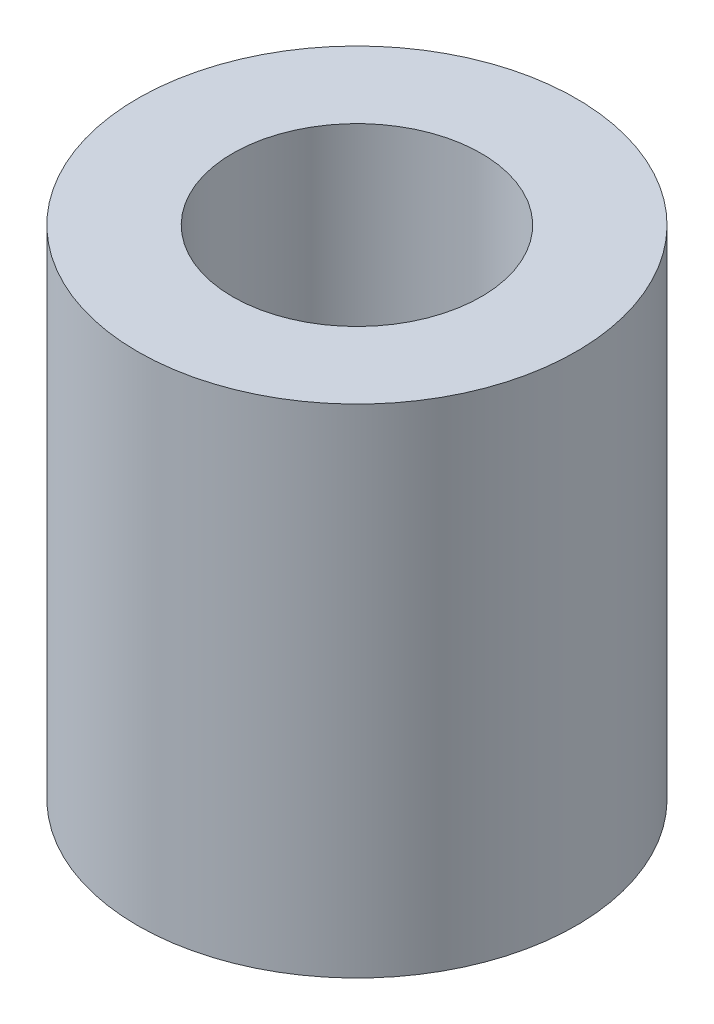
from build123d import *

# Parameters (mm, degrees)
SKETCH1_R           = 7.5
SKETCH1_R_2         = 4.25
BOSS_EXTRUDE1_DEPTH = 17


with BuildPart() as part:
    # Sketch1 → Boss-Extrude1 (new body)
    with BuildSketch(Plane(origin=(0, 0, 0), x_dir=(1, 0, 0), z_dir=(0, 1, 0))):
        Circle(SKETCH1_R)
        Circle(SKETCH1_R_2, mode=Mode.SUBTRACT)
    extrude(amount=BOSS_EXTRUDE1_DEPTH)


solid = part.part
